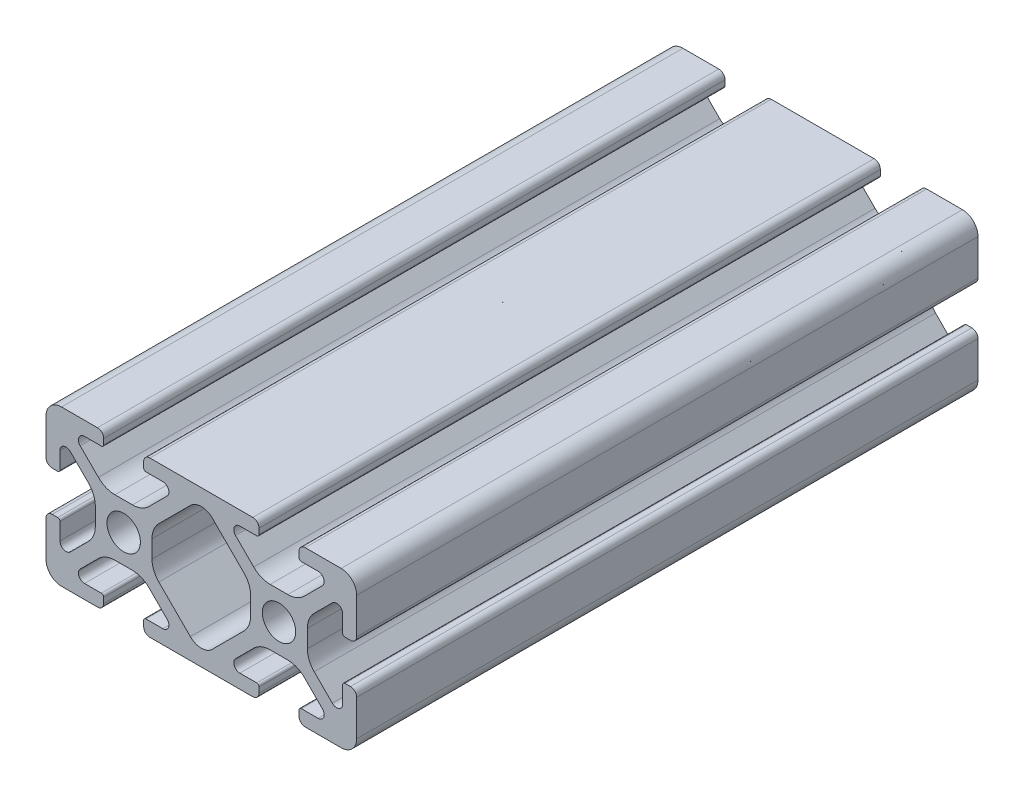
from build123d import *

# Parameters (mm, degrees)
CROQUIS3_R              = 2.15
SALIENTE_EXTRUIR1_DEPTH = 80


with BuildPart() as part:
    # Croquis3 → Saliente-Extruir1 (new body)
    with BuildSketch(Plane.XY):
        with BuildLine():
            Line((-2.574814133, 9.2), (-2.574814133, 8.5))
            ThreePointArc((-2.574814133, 8.5), (-2.662682099, 8.287867966), (-2.874814133, 8.2))
            Line((-2.874814133, 8.2), (-5.044814133, 8.2))
            ThreePointArc((-5.044814133, 8.2), (-5.765448465, 7.718473047), (-5.596326761, 6.868426051))
            Line((-5.596326761, 6.868426051), (-3.255673209, 4.528032719))
            ThreePointArc((-3.255673209, 4.528032719), (-2.282627587, 3.878186348), (-1.135, 3.65))
            Line((-1.135, 3.65), (1.135, 3.65))
            ThreePointArc((1.135, 3.65), (2.282627587, 3.878186348), (3.255673209, 4.528032719))
            Line((3.255673209, 4.528032719), (5.596326761, 6.868426051))
            ThreePointArc((5.596326761, 6.868426051), (5.765448465, 7.718473047), (5.044814133, 8.2))
            Line((5.044814133, 8.2), (2.874814133, 8.2))
            ThreePointArc((2.874814133, 8.2), (2.662682099, 8.287867966), (2.574814133, 8.5))
            Line((2.574814133, 8.5), (2.574814133, 9.2))
            ThreePointArc((2.574814133, 9.2), (2.809128708, 9.765685425), (3.374814133, 10))
            Line((3.374814133, 10), (16.625185867, 10))
            ThreePointArc((16.625185867, 10), (17.190871292, 9.765685425), (17.425185867, 9.2))
            Line((17.425185867, 9.2), (17.425185867, 8.5))
            ThreePointArc((17.425185867, 8.5), (17.337317901, 8.287867966), (17.125185867, 8.2))
            Line((17.125185867, 8.2), (14.955185867, 8.2))
            ThreePointArc((14.955185867, 8.2), (14.234551535, 7.718473047), (14.403673239, 6.868426051))
            Line((14.403673239, 6.868426051), (16.744326791, 4.528032719))
            ThreePointArc((16.744326791, 4.528032719), (17.717372413, 3.878186348), (18.865, 3.65))
            Line((18.865, 3.65), (21.135, 3.65))
            ThreePointArc((21.135, 3.65), (22.282627587, 3.878186348), (23.255673209, 4.528032719))
            Line((23.255673209, 4.528032719), (25.596326761, 6.868426051))
            ThreePointArc((25.596326761, 6.868426051), (25.765448465, 7.718473047), (25.044814133, 8.2))
            Line((25.044814133, 8.2), (22.874814133, 8.2))
            ThreePointArc((22.874814133, 8.2), (22.662682099, 8.287867966), (22.574814133, 8.5))
            Line((22.574814133, 8.5), (22.574814133, 9.2))
            ThreePointArc((22.574814133, 9.2), (22.809128708, 9.765685425), (23.374814133, 10))
            Line((23.374814133, 10), (28, 10))
            ThreePointArc((28, 10), (29.414213562, 9.414213562), (30, 8))
            Line((30, 8), (30, 3.374814133))
            ThreePointArc((30, 3.374814133), (29.765685425, 2.809128708), (29.2, 2.574814133))
            Line((29.2, 2.574814133), (28.5, 2.574814133))
            ThreePointArc((28.5, 2.574814133), (28.287867966, 2.662682099), (28.2, 2.874814133))
            Line((28.2, 2.874814133), (28.2, 5.044814133))
            ThreePointArc((28.2, 5.044814133), (27.718473047, 5.765448465), (26.868426051, 5.596326761))
            Line((26.868426051, 5.596326761), (24.528032719, 3.255673209))
            ThreePointArc((24.528032719, 3.255673209), (23.878186348, 2.282627587), (23.65, 1.135))
            Line((23.65, 1.135), (23.65, -1.135))
            ThreePointArc((23.65, -1.135), (23.878186348, -2.282627587), (24.528032719, -3.255673209))
            Line((24.528032719, -3.255673209), (26.868426051, -5.596326761))
            ThreePointArc((26.868426051, -5.596326761), (27.718473047, -5.765448465), (28.2, -5.044814133))
            Line((28.2, -5.044814133), (28.2, -2.874814133))
            ThreePointArc((28.2, -2.874814133), (28.287867966, -2.662682099), (28.5, -2.574814133))
            Line((28.5, -2.574814133), (29.2, -2.574814133))
            ThreePointArc((29.2, -2.574814133), (29.765685425, -2.809128708), (30, -3.374814133))
            Line((30, -3.374814133), (30, -8))
            ThreePointArc((30, -8), (29.414213562, -9.414213562), (28, -10))
            Line((28, -10), (23.374814133, -10))
            ThreePointArc((23.374814133, -10), (22.809128708, -9.765685425), (22.574814133, -9.2))
            Line((22.574814133, -9.2), (22.574814133, -8.5))
            ThreePointArc((22.574814133, -8.5), (22.662682099, -8.287867966), (22.874814133, -8.2))
            Line((22.874814133, -8.2), (25.044814133, -8.2))
            ThreePointArc((25.044814133, -8.2), (25.765448465, -7.718473047), (25.596326761, -6.868426051))
            Line((25.596326761, -6.868426051), (23.255673209, -4.528032719))
            ThreePointArc((23.255673209, -4.528032719), (22.282627587, -3.878186348), (21.135, -3.65))
            Line((21.135, -3.65), (18.865, -3.65))
            ThreePointArc((18.865, -3.65), (17.717372413, -3.878186348), (16.744326791, -4.528032719))
            Line((16.744326791, -4.528032719), (14.403673239, -6.868426051))
            ThreePointArc((14.403673239, -6.868426051), (14.234551535, -7.718473047), (14.955185867, -8.2))
            Line((14.955185867, -8.2), (17.125185867, -8.2))
            ThreePointArc((17.125185867, -8.2), (17.337317901, -8.287867966), (17.425185867, -8.5))
            Line((17.425185867, -8.5), (17.425185867, -9.2))
            ThreePointArc((17.425185867, -9.2), (17.190871292, -9.765685425), (16.625185867, -10))
            Line((16.625185867, -10), (3.374814133, -10))
            ThreePointArc((3.374814133, -10), (2.809128708, -9.765685425), (2.574814133, -9.2))
            Line((2.574814133, -9.2), (2.574814133, -8.5))
            ThreePointArc((2.574814133, -8.5), (2.662682099, -8.287867966), (2.874814133, -8.2))
            Line((2.874814133, -8.2), (5.044814133, -8.2))
            ThreePointArc((5.044814133, -8.2), (5.765448465, -7.718473047), (5.596326761, -6.868426051))
            Line((5.596326761, -6.868426051), (3.255673209, -4.528032719))
            ThreePointArc((3.255673209, -4.528032719), (2.282627587, -3.878186348), (1.135, -3.65))
            Line((1.135, -3.65), (-1.135, -3.65))
            ThreePointArc((-1.135, -3.65), (-2.282627587, -3.878186348), (-3.255673209, -4.528032719))
            Line((-3.255673209, -4.528032719), (-5.596326761, -6.868426051))
            ThreePointArc((-5.596326761, -6.868426051), (-5.765448465, -7.718473047), (-5.044814133, -8.2))
            Line((-5.044814133, -8.2), (-2.874814133, -8.2))
            ThreePointArc((-2.874814133, -8.2), (-2.662682099, -8.287867966), (-2.574814133, -8.5))
            Line((-2.574814133, -8.5), (-2.574814133, -9.2))
            ThreePointArc((-2.574814133, -9.2), (-2.809128708, -9.765685425), (-3.374814133, -10))
            Line((-3.374814133, -10), (-8, -10))
            ThreePointArc((-8, -10), (-9.414213562, -9.414213562), (-10, -8))
            Line((-10, -8), (-10, -3.374814133))
            ThreePointArc((-10, -3.374814133), (-9.765685425, -2.809128708), (-9.2, -2.574814133))
            Line((-9.2, -2.574814133), (-8.5, -2.574814133))
            ThreePointArc((-8.5, -2.574814133), (-8.287867966, -2.662682099), (-8.2, -2.874814133))
            Line((-8.2, -2.874814133), (-8.2, -5.044814133))
            ThreePointArc((-8.2, -5.044814133), (-7.718473047, -5.765448465), (-6.868426051, -5.596326761))
            Line((-6.868426051, -5.596326761), (-4.528032719, -3.255673209))
            ThreePointArc((-4.528032719, -3.255673209), (-3.878186348, -2.282627587), (-3.65, -1.135))
            Line((-3.65, -1.135), (-3.65, 1.135))
            ThreePointArc((-3.65, 1.135), (-3.878186348, 2.282627587), (-4.528032719, 3.255673209))
            Line((-4.528032719, 3.255673209), (-6.868426051, 5.596326761))
            ThreePointArc((-6.868426051, 5.596326761), (-7.718473047, 5.765448465), (-8.2, 5.044814133))
            Line((-8.2, 5.044814133), (-8.2, 2.874814133))
            ThreePointArc((-8.2, 2.874814133), (-8.287867966, 2.662682099), (-8.5, 2.574814133))
            Line((-8.5, 2.574814133), (-9.2, 2.574814133))
            ThreePointArc((-9.2, 2.574814133), (-9.765685425, 2.809128708), (-10, 3.374814133))
            Line((-10, 3.374814133), (-10, 8))
            ThreePointArc((-10, 8), (-9.414213562, 9.414213562), (-8, 10))
            Line((-8, 10), (-3.374814133, 10))
            ThreePointArc((-3.374814133, 10), (-2.809128708, 9.765685425), (-2.574814133, 9.2))
        make_face()
        Circle(CROQUIS3_R, mode=Mode.SUBTRACT)
        with Locations((20, 0)):
            Circle(CROQUIS3_R, mode=Mode.SUBTRACT)
        with BuildLine():
            Line((4.528394658, 3.25516976), (8.586400769, 7.314749345))
            ThreePointArc((8.586400769, 7.314749345), (9.234932122, 7.748324734), (10, 7.900809736))
            ThreePointArc((10, 7.900809736), (10.765067878, 7.748324734), (11.413599231, 7.314749345))
            Line((11.413599231, 7.314749345), (15.471605342, 3.25516976))
            ThreePointArc((15.471605342, 3.25516976), (16.121559892, 2.282196395), (16.349873833, 1.134594184))
            Line((16.349873833, 1.134594184), (16.349873833, -1.134594184))
            ThreePointArc((16.349873833, -1.134594184), (16.121559892, -2.282196395), (15.471605342, -3.25516976))
            Line((15.471605342, -3.25516976), (11.413599231, -7.314749345))
            ThreePointArc((11.413599231, -7.314749345), (10, -7.900441833), (8.586400769, -7.314749345))
            Line((8.586400769, -7.314749345), (4.528394658, -3.25516976))
            ThreePointArc((4.528394658, -3.25516976), (3.878440108, -2.282196395), (3.650126167, -1.134594184))
            Line((3.650126167, -1.134594184), (3.650126167, 1.134594184))
            ThreePointArc((3.650126167, 1.134594184), (3.878440108, 2.282196395), (4.528394658, 3.25516976))
        make_face(mode=Mode.SUBTRACT)
    extrude(amount=SALIENTE_EXTRUIR1_DEPTH)


solid = part.part
